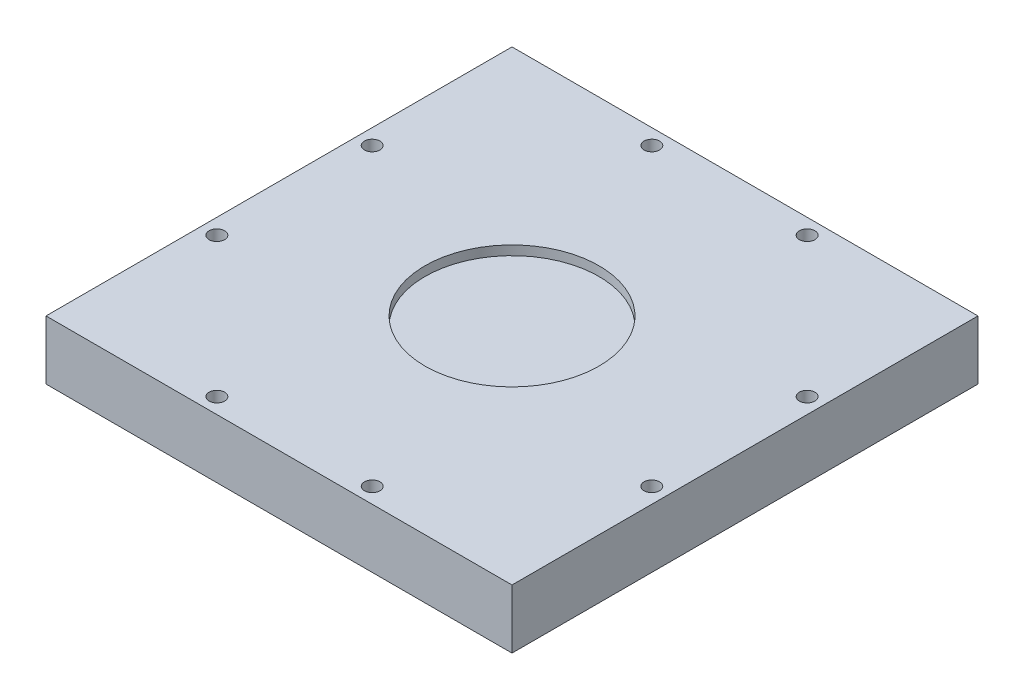
from build123d import *

# Parameters (mm, degrees)
SKETCH1_W           = 150
SKETCH1_H           = 150
BOSS_EXTRUDE1_DEPTH = 19
SKETCH2_R           = 28
CUT_EXTRUDE1_DEPTH  = 3
SKETCH3_R           = 2.5
CUT_EXTRUDE2_DEPTH  = 5
CIRPATTERN1_COUNT   = 4


with BuildPart() as part:
    # Sketch1 → Boss-Extrude1 (new body)
    with BuildSketch(Plane(origin=(0, 0, 0), x_dir=(1, 0, 0), z_dir=(0, 1, 0))):
        with Locations((75, 75)):
            Rectangle(SKETCH1_W, SKETCH1_H)
    extrude(amount=BOSS_EXTRUDE1_DEPTH)

    # Sketch2 → Cut-Extrude1 (cut)
    with BuildSketch(Plane(origin=(0, 19, 0), x_dir=(1, 0, 0), z_dir=(0, 1, 0))):
        with Locations((75, 75)):
            Circle(SKETCH2_R)
    extrude(amount=-CUT_EXTRUDE1_DEPTH, mode=Mode.SUBTRACT)

    # Sketch3 → Cut-Extrude2 (cut)
    with BuildSketch(Plane(origin=(0, 19, 0), x_dir=(1, 0, 0), z_dir=(0, 1, 0))):
        with Locations((100, 5)):
            Circle(SKETCH3_R)
        with Locations((50, 5)):
            Circle(SKETCH3_R)
    cut_extrude2 = extrude(amount=-CUT_EXTRUDE2_DEPTH, mode=Mode.SUBTRACT)

    # CirPattern1: Cut-Extrude2 ×4 about axis
    cirpattern1_axis = Axis((75, 16, -75), (0, 1, 0))
    for i in range(1, CIRPATTERN1_COUNT):
        add(cut_extrude2.rotate(cirpattern1_axis, i * 360 / CIRPATTERN1_COUNT), mode=Mode.SUBTRACT)


solid = part.part
